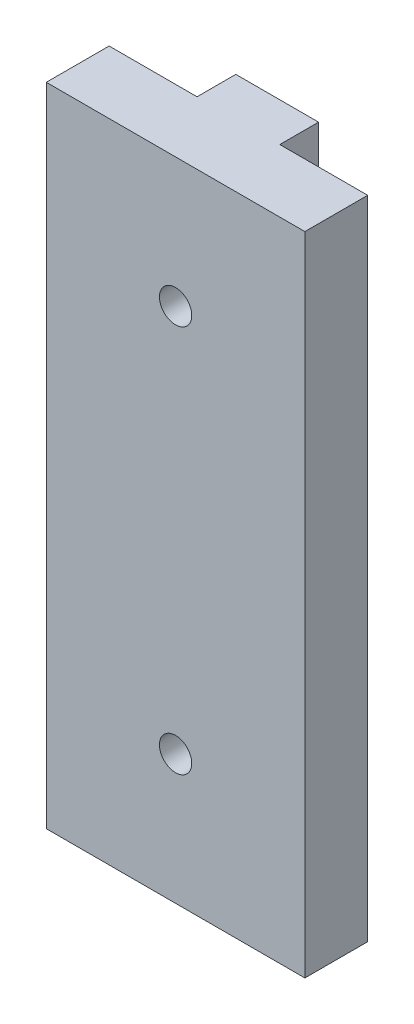
from build123d import *

# Parameters (mm, degrees)
BOSS_EXTRUDE1_DEPTH = 63.5
SKETCH3_R           = 1.5875
CUT_EXTRUDE1_DEPTH  = 63.5


with BuildPart() as part:
    # Sketch2 → Boss-Extrude1 (new body)
    with BuildSketch(Plane(origin=(0, 0, 0), x_dir=(1, 0, 0), z_dir=(0, 1, 0))):
        Polygon((16.764, 6.1722), (25.4, 6.1722), (25.4, 0), (0, 0), (0, 6.1722), (8.636, 6.1722), (8.636, 9.9822), (16.764, 9.9822), align=None)
    extrude(amount=BOSS_EXTRUDE1_DEPTH)

    # Sketch3 → Cut-Extrude1 (cut)
    with BuildSketch(Plane.XY):
        with Locations((12.7, 50.8)):
            Circle(SKETCH3_R)
        with Locations((12.7, 12.7)):
            Circle(SKETCH3_R)
    extrude(amount=-CUT_EXTRUDE1_DEPTH, mode=Mode.SUBTRACT)


solid = part.part
